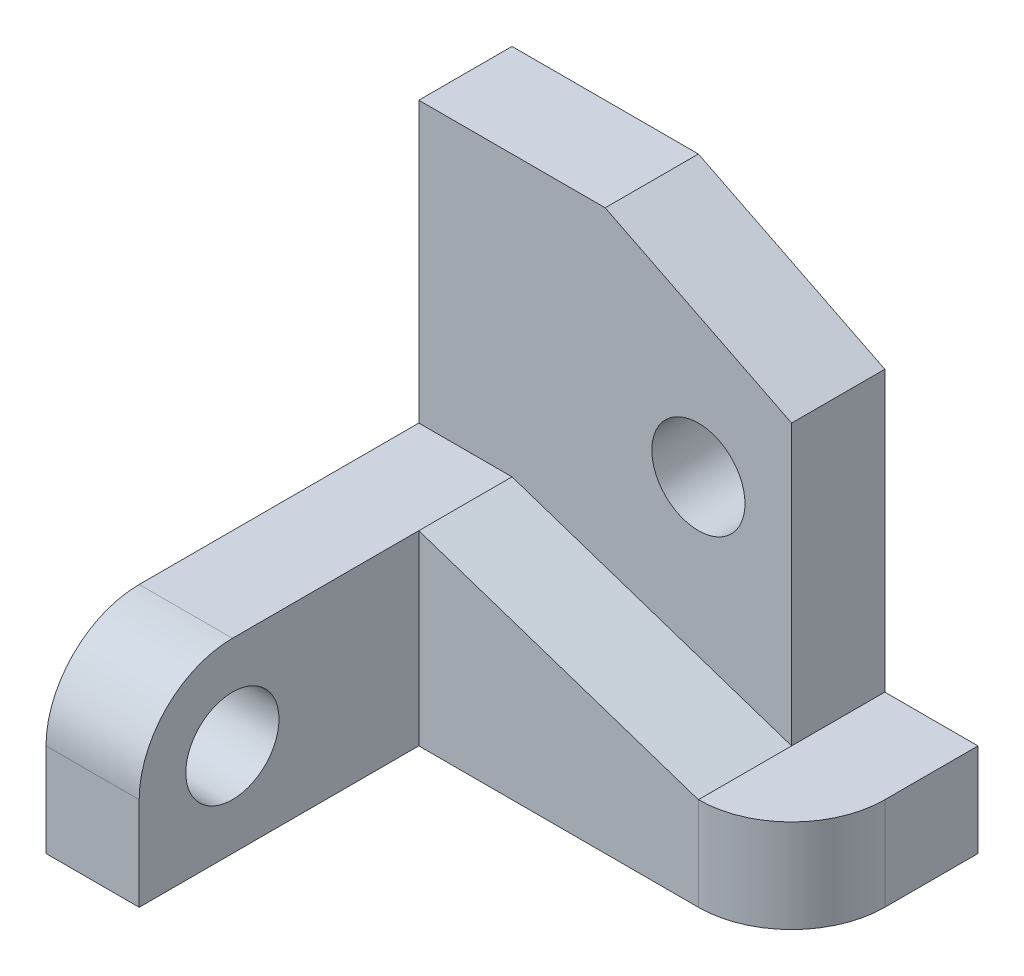
from build123d import *

# Parameters (mm, degrees)
EXTRUDE_1_DEPTH     = 5
SKETCH_1_3_W        = 20
SKETCH_1_3_H        = 5
EXTRUDE_2_DEPTH     = 10
SKETCH_1_4_W        = 20
SKETCH_1_4_H        = 5
EXTRUDE_3_DEPTH     = 25
SKETCH_2_R          = 2.5
CUT_EXTRUDE_1_DEPTH = 25
CUT_EXTRUDE_2_DEPTH = 5
SKETCH_4_R          = 2.5
EXTRUDE_4_DEPTH     = 5


with BuildPart() as part:
    # 草圖1 → 填料-伸長1 (new body)
    with BuildSketch(Plane(origin=(0, 0, 0), x_dir=(1, 0, 0), z_dir=(0, 1, 0))):
        with BuildLine():
            Line((20, 10), (20, 5))
            Line((20, 5), (20, 0))
            ThreePointArc((20, 0), (23.535533906, 1.464466094), (25, 5))
            Line((25, 5), (25, 10))
            Line((25, 10), (20, 10))
        make_face()
    extrude(amount=EXTRUDE_1_DEPTH)

    # 草圖1<3> → 填料-伸長2 (add)
    with BuildSketch(Plane(origin=(0, 0, 0), x_dir=(1, 0, 0), z_dir=(0, 1, 0))):
        with Locations((10, 2.5)):
            Rectangle(SKETCH_1_3_W, SKETCH_1_3_H)
    extrude(amount=EXTRUDE_2_DEPTH)

    # 草圖1<4> → 填料-伸長3 (add)
    with BuildSketch(Plane(origin=(0, 0, 0), x_dir=(1, 0, 0), z_dir=(0, 1, 0))):
        with Locations((10, 7.5)):
            Rectangle(SKETCH_1_4_W, SKETCH_1_4_H)
    extrude(amount=EXTRUDE_3_DEPTH)

    # 草圖2 → 除料-伸長1 (cut)
    with BuildSketch(Plane.XY.offset(-5)):
        with Locations((15, 15)):
            Circle(SKETCH_2_R)
        Polygon((10, 25), (20, 20), (20, 25), align=None)
    extrude(amount=-CUT_EXTRUDE_1_DEPTH, mode=Mode.SUBTRACT)

    # 草圖3 → 除料-伸長2 (cut)
    with BuildSketch(Plane.XY):
        Polygon((20, 5), (5, 10), (20, 10), align=None)
    extrude(amount=-CUT_EXTRUDE_2_DEPTH, mode=Mode.SUBTRACT)

    # 草圖4 → 填料-伸長4 (add)
    with BuildSketch(Plane(origin=(0, 0, 0), x_dir=(0, 0, -1), z_dir=(1, 0, 0))):
        with BuildLine():
            Line((0, 10), (-10, 10))
            ThreePointArc((-10, 10), (-13.535533906, 8.535533906), (-15, 5))
            Line((-15, 5), (-15, 0))
            Line((-15, 0), (0, 0))
            Line((0, 0), (0, 10))
        make_face()
        with Locations((-10, 5)):
            Circle(SKETCH_4_R, mode=Mode.SUBTRACT)
    extrude(amount=EXTRUDE_4_DEPTH)


solid = part.part
